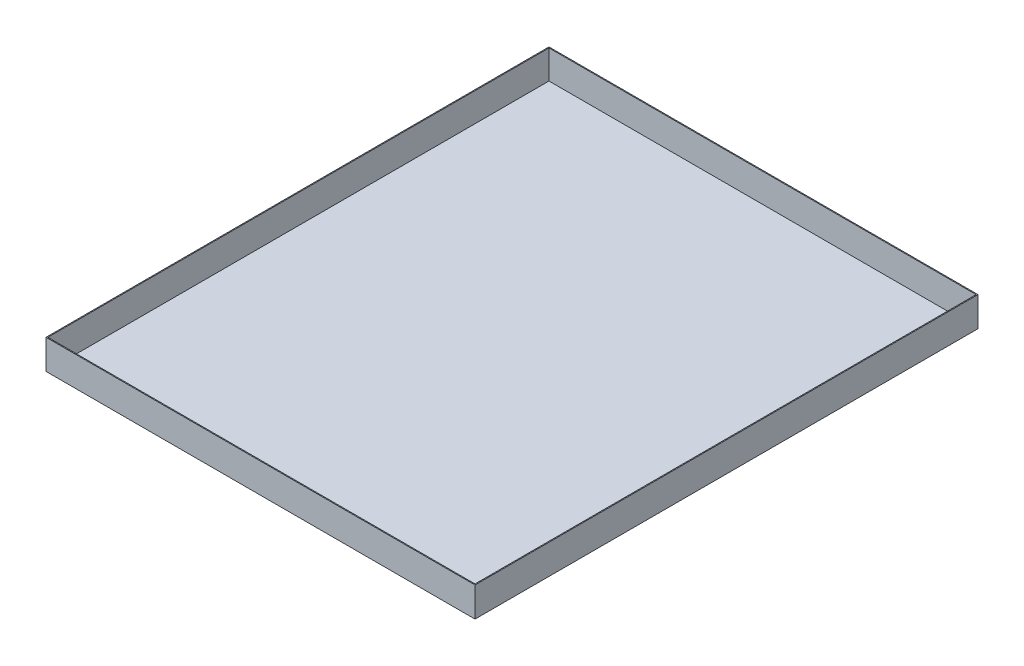
from build123d import *

# Parameters (mm, degrees)
SKETCH1_W           = 736.6
SKETCH1_H           = 863.6
BOSS_EXTRUDE1_DEPTH = 50.8
SHELL1_T            = -1.5875


with BuildPart() as part:
    # Sketch1 → Boss-Extrude1 (new body)
    with BuildSketch(Plane(origin=(0, 0, 0), x_dir=(1, 0, 0), z_dir=(0, 1, 0))):
        Rectangle(SKETCH1_W, SKETCH1_H)
    extrude(amount=BOSS_EXTRUDE1_DEPTH)

    # Shell1
    shell1_openings = [part.faces().sort_by_distance(p)[0] for p in [
        (0, 50.8, 0),
    ]]
    offset(amount=SHELL1_T, openings=shell1_openings, kind=Kind.INTERSECTION)


solid = part.part
